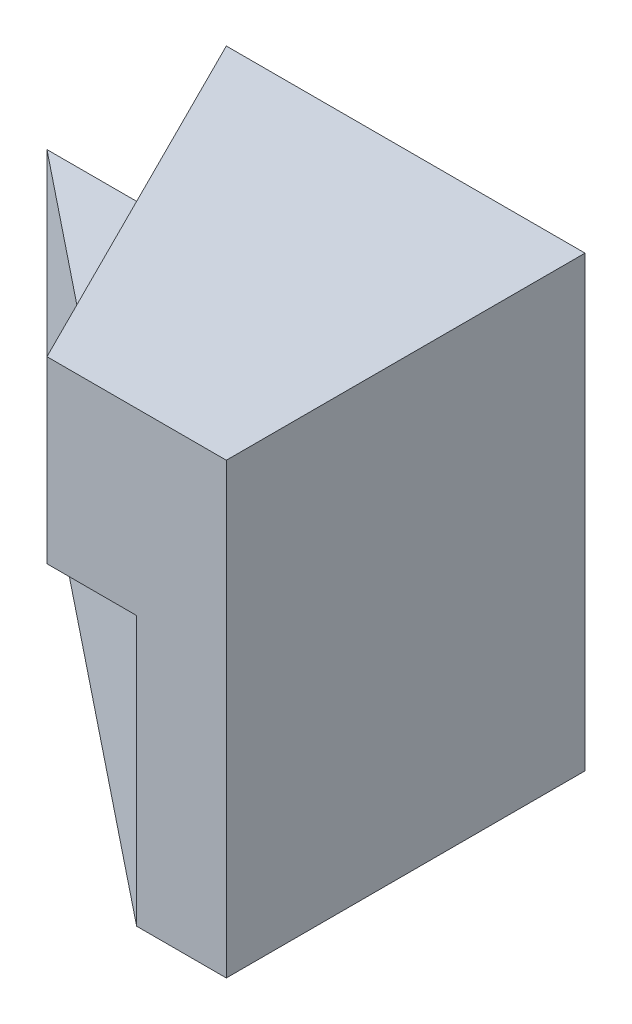
from build123d import *

# Parameters (mm, degrees)
BOSS_EXTRUDE1_DEPTH = 3
BOSS_EXTRUDE2_DEPTH = 4
CUT_EXTRUDE2_DEPTH  = 2


with BuildPart() as part:
    # Sketch1 → Boss-Extrude1 (new body)
    with BuildSketch(Plane(origin=(0, 0, 0), x_dir=(1, 0, 0), z_dir=(0, 1, 0))):
        Polygon((0, 0), (-5, 4), (0, 4), align=None)
    extrude(amount=BOSS_EXTRUDE1_DEPTH)

    # Sketch2 → Boss-Extrude2 (add)
    with BuildSketch(Plane(origin=(0, 0, -4), x_dir=(-1, 0, 0), z_dir=(0, 0, -1))):
        Polygon((1, 5), (3, 5), (3, 3), (0, 3), (0, 0), (-1, 0), (-1, 5), align=None)
    extrude(amount=-BOSS_EXTRUDE2_DEPTH)

    # Sketch4 → Cut-Extrude2 (cut)
    with BuildSketch(Plane(origin=(0, 5, 0), x_dir=(1, 0, 0), z_dir=(0, 1, 0))):
        Polygon((-3, 4), (-1, 0), (-3, 0), align=None)
    extrude(amount=-CUT_EXTRUDE2_DEPTH, mode=Mode.SUBTRACT)


solid = part.part
